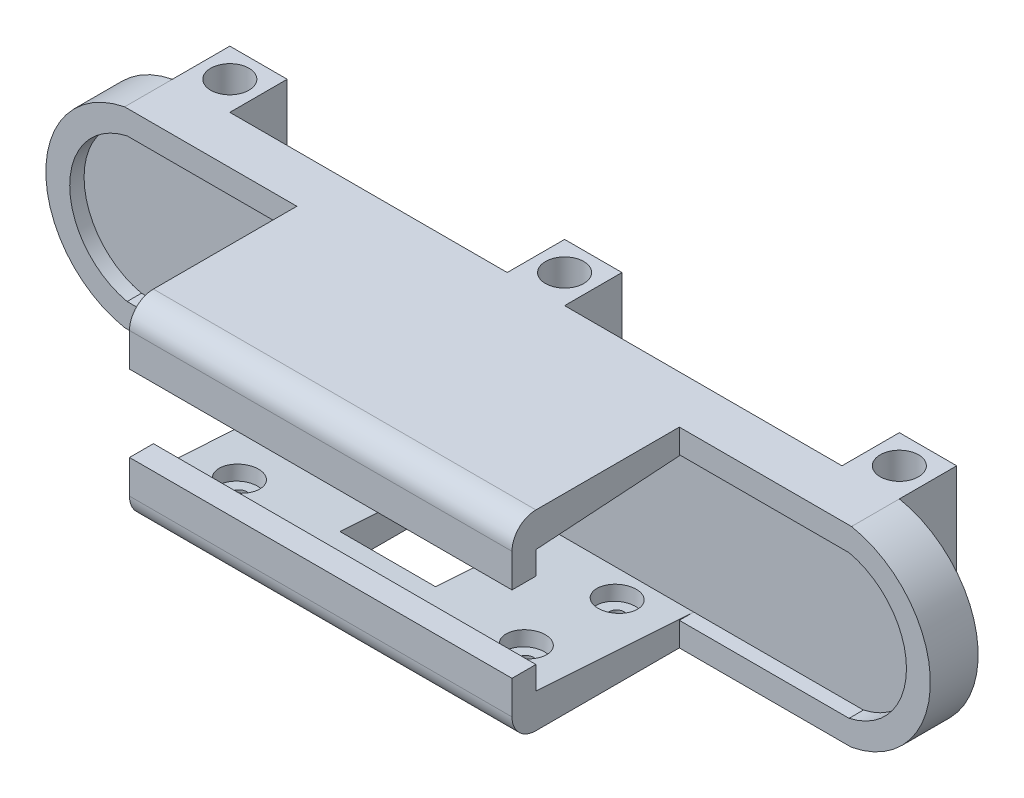
from build123d import *

# Parameters (mm, degrees)
ESTRUSIONE_ESTRUSIONE1_DEPTH  = 10
TAGLIO_ESTRUSIONE1_DEPTH      = 3
SCHIZZO4_W                    = 80
SCHIZZO4_H                    = 5
ESTRUSIONE_ESTRUSIONE2_DEPTH  = 35
ESTRUSIONE_ESTRUSIONE4_DEPTH  = 80
SCHIZZO7_W                    = 80
SCHIZZO7_H                    = 5
ESTRUSIONE_ESTRUSIONE5_DEPTH  = 7
TAGLIO_ESTRUSIONE2_REACH      = 42
SCHIZZO8_R                    = 1.5
RACCORDO1_R                   = 5
RACCORDO2_R                   = 5
TAGLIO_ESTRUSIONE3_DEPTH      = 1
TAGLIO_ESTRUSIONE3_DEPTH_BACK = 10
SCHIZZO11_R                   = 4
TAGLIO_ESTRUSIONE4_DEPTH      = 3
SCHIZZO12_W                   = 12
SCHIZZO12_H                   = 12
ESTRUSIONE_ESTRUSIONE6_DEPTH  = 40
SCHIZZO13_R                   = 1.5
TAGLIO_ESTRUSIONE5_DEPTH      = 41
SCHIZZO14_R                   = 4
TAGLIO_ESTRUSIONE6_DEPTH      = 10


with BuildPart() as part:
    # Schizzo1 → Estrusione-Estrusione1 (new body)
    with BuildSketch(Plane.XY):
        with BuildLine():
            Line((-76.016095604, 20), (76.016095604, 20))
            ThreePointArc((76.016095604, 20), (92.5, 0), (76.016095604, -20))
            Line((76.016095604, -20), (-76.016095604, -20))
            ThreePointArc((-76.016095604, -20), (-92.5, 0), (-76.016095604, 20))
        make_face()
    extrude(amount=ESTRUSIONE_ESTRUSIONE1_DEPTH)

    # Schizzo3 → Taglio-Estrusione1 (cut)
    with BuildSketch(Plane.XY.offset(10)):
        with BuildLine():
            Line((-75.5, -15), (75.5, -15))
            ThreePointArc((75.5, -15), (87.5, 0), (75.5, 15))
            Line((75.5, 15), (-75.5, 15))
            ThreePointArc((-75.5, 15), (-87.5, 0), (-75.5, -15))
        make_face()
    extrude(amount=-TAGLIO_ESTRUSIONE1_DEPTH, mode=Mode.SUBTRACT)

    # Schizzo4 → Estrusione-Estrusione2 (add)
    with BuildSketch(Plane.XY.offset(10)):
        with Locations((0, -17.5)):
            Rectangle(SCHIZZO4_W, SCHIZZO4_H)
    estrusione_estrusione2 = extrude(amount=ESTRUSIONE_ESTRUSIONE2_DEPTH)

    # Schizzo6 → Estrusione-Estrusione4 (add)
    with BuildSketch(Plane(origin=(40, 0, 0), x_dir=(0, 0, -1), z_dir=(1, 0, 0))):
        Polygon((-40, -15), (-40, -12.81), (-7, -15), align=None)
    estrusione_estrusione4 = extrude(amount=-ESTRUSIONE_ESTRUSIONE4_DEPTH)

    # Schizzo7 → Estrusione-Estrusione5 (add)
    with BuildSketch(Plane(origin=(0, -15, 0), x_dir=(1, 0, 0), z_dir=(0, 1, 0))):
        with Locations((0, -42.5)):
            Rectangle(SCHIZZO7_W, SCHIZZO7_H)
    estrusione_estrusione5 = extrude(amount=ESTRUSIONE_ESTRUSIONE5_DEPTH)

    # Schizzo8 → Taglio-Estrusione2 (cut, up to next)
    with BuildSketch(Plane.XZ.offset(20), mode=Mode.PRIVATE) as taglio_estrusione2_sk1:
        with Locations((-30, 13)):
            Circle(SCHIZZO8_R)
    taglio_estrusione2_tool1 = extrude(taglio_estrusione2_sk1.sketch, amount=-TAGLIO_ESTRUSIONE2_REACH, mode=Mode.PRIVATE) & part.part
    add(taglio_estrusione2_tool1.solids().sort_by_distance((-30, -20, 13))[0], mode=Mode.SUBTRACT)
    # Schizzo8 → Taglio-Estrusione2 (cut, up to next)
    with BuildSketch(Plane.XZ.offset(20), mode=Mode.PRIVATE) as taglio_estrusione2_sk2:
        with Locations((-30, 32)):
            Circle(SCHIZZO8_R)
    taglio_estrusione2_tool2 = extrude(taglio_estrusione2_sk2.sketch, amount=-TAGLIO_ESTRUSIONE2_REACH, mode=Mode.PRIVATE) & part.part
    add(taglio_estrusione2_tool2.solids().sort_by_distance((-30, -20, 32))[0], mode=Mode.SUBTRACT)
    # Schizzo8 → Taglio-Estrusione2 (cut, up to next)
    with BuildSketch(Plane.XZ.offset(20), mode=Mode.PRIVATE) as taglio_estrusione2_sk3:
        with Locations((30, 13)):
            Circle(SCHIZZO8_R)
    taglio_estrusione2_tool3 = extrude(taglio_estrusione2_sk3.sketch, amount=-TAGLIO_ESTRUSIONE2_REACH, mode=Mode.PRIVATE) & part.part
    add(taglio_estrusione2_tool3.solids().sort_by_distance((30, -20, 13))[0], mode=Mode.SUBTRACT)
    # Schizzo8 → Taglio-Estrusione2 (cut, up to next)
    with BuildSketch(Plane.XZ.offset(20), mode=Mode.PRIVATE) as taglio_estrusione2_sk4:
        with Locations((30, 32)):
            Circle(SCHIZZO8_R)
    taglio_estrusione2_tool4 = extrude(taglio_estrusione2_sk4.sketch, amount=-TAGLIO_ESTRUSIONE2_REACH, mode=Mode.PRIVATE) & part.part
    add(taglio_estrusione2_tool4.solids().sort_by_distance((30, -20, 32))[0], mode=Mode.SUBTRACT)

    # Specchia1: Estrusione-Estrusione2, Estrusione-Estrusione4, Estrusione-Estrusione5 across plane
    add(estrusione_estrusione2.mirror(Plane.ZX))
    add(estrusione_estrusione4.mirror(Plane.ZX))
    add(estrusione_estrusione5.mirror(Plane.ZX))

    # Raccordo1
    raccordo1_edges = [part.edges().sort_by_distance(p)[0] for p in [
        (0, -20, 45),
    ]]
    fillet(raccordo1_edges, radius=RACCORDO1_R)

    # Raccordo2
    raccordo2_edges = [part.edges().sort_by_distance(p)[0] for p in [
        (0, 20, 45),
    ]]
    fillet(raccordo2_edges, radius=RACCORDO2_R)

    # Schizzo9 → Taglio-Estrusione3 (cut, two sides)
    with BuildSketch(Plane.XZ.offset(20)) as taglio_estrusione3_sk:
        Polygon((-4, 11), (-4, 3), (4, 3), (4, 11), (10, 11), (10, 31), (-10, 31), (-10, 11), align=None)
    extrude(amount=TAGLIO_ESTRUSIONE3_DEPTH, mode=Mode.SUBTRACT)
    extrude(taglio_estrusione3_sk.sketch, amount=-TAGLIO_ESTRUSIONE3_DEPTH_BACK, mode=Mode.SUBTRACT)

    # Schizzo11 → Taglio-Estrusione4 (cut)
    with BuildSketch(Plane(origin=(0, -15.396736192, 1.021783402), x_dir=(1, 0, 0), z_dir=(0, 0.997805181, -0.06621798))):
        with Locations((-30, -12.004564445)):
            Circle(SCHIZZO11_R)
        with Locations((-30, -31.046357736)):
            Circle(SCHIZZO11_R)
        with Locations((30, -31.046357736)):
            Circle(SCHIZZO11_R)
        with Locations((30, -12.004564445)):
            Circle(SCHIZZO11_R)
    extrude(amount=-TAGLIO_ESTRUSIONE4_DEPTH, mode=Mode.SUBTRACT)

    # Schizzo12 → Estrusione-Estrusione6 (add)
    with BuildSketch(Plane.XZ.offset(20)):
        with Locations((70.016095604, -6)):
            Rectangle(SCHIZZO12_W, SCHIZZO12_H)
        with Locations((-70.016095604, -6)):
            Rectangle(SCHIZZO12_W, SCHIZZO12_H)
        with Locations((0, -6)):
            Rectangle(SCHIZZO12_W, SCHIZZO12_H)
    extrude(amount=-ESTRUSIONE_ESTRUSIONE6_DEPTH)

    # Schizzo13 → Taglio-Estrusione5 (cut, through all)
    with BuildSketch(Plane.XZ.offset(20)):
        with Locations((-70.016095604, -6)):
            Circle(SCHIZZO13_R)
        with Locations((0, -6)):
            Circle(SCHIZZO13_R)
        with Locations((70.016095604, -6)):
            Circle(SCHIZZO13_R)
    extrude(amount=-TAGLIO_ESTRUSIONE5_DEPTH, mode=Mode.SUBTRACT)

    # Schizzo14 → Taglio-Estrusione6 (cut)
    with BuildSketch(Plane.XZ.offset(20)):
        with Locations((-70.016095604, -6)):
            Circle(SCHIZZO14_R)
        with Locations((0, -6)):
            Circle(SCHIZZO14_R)
        with Locations((70.016095604, -6)):
            Circle(SCHIZZO14_R)
    taglio_estrusione6 = extrude(amount=-TAGLIO_ESTRUSIONE6_DEPTH, mode=Mode.SUBTRACT)

    # Specchia2: Taglio-Estrusione6 across plane
    add(taglio_estrusione6.mirror(Plane.ZX), mode=Mode.SUBTRACT)


solid = part.part
